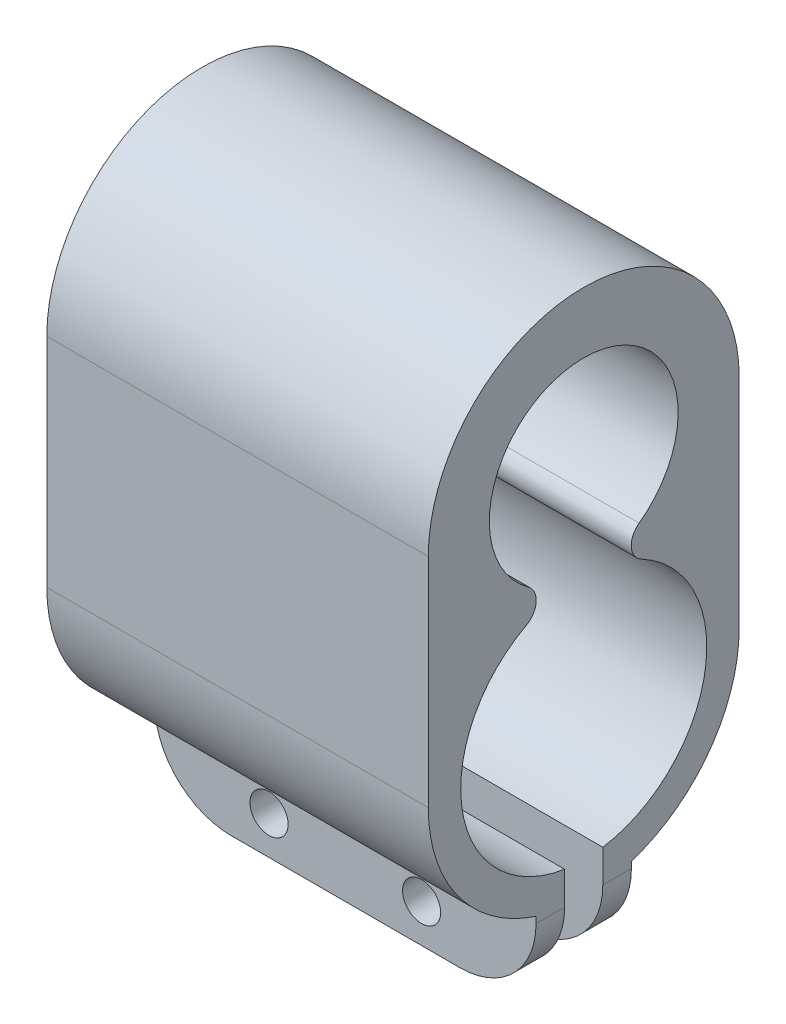
from build123d import *

# Parameters (mm, degrees)
BOSS_EXTRUDE2_DEPTH = 20
SKETCH2_W           = 2
SKETCH2_H           = 9.242730417
CUT_EXTRUDE1_DEPTH  = 20
SKETCH3_W           = 1.5
SKETCH3_H           = 5.716408543
BOSS_EXTRUDE3_DEPTH = 20
SKETCH4_R           = 1
CUT_EXTRUDE2_DEPTH  = 11.65
FILLET1_R           = 4


with BuildPart() as part:
    # Sketch1 → Boss-Extrude2 (new body)
    with BuildSketch(Plane(origin=(0, 0, 0), x_dir=(0, 0, -1), z_dir=(1, 0, 0))):
        with BuildLine():
            Line((8.15, 11.4), (8.15, 0))
            ThreePointArc((8.15, 0), (0, -8.15), (-8.15, 0))
            Line((-8.15, 0), (-8.15, 11.4))
            ThreePointArc((-8.15, 11.4), (0, 19.55), (8.15, 11.4))
        make_face()
        with BuildLine():
            ThreePointArc((2.904067302, 7.391397612), (0, 16.35), (-2.904067302, 7.391397612))
            ThreePointArc((-2.904067302, 7.391397612), (-2.493172041, 6.511986737), (-3.022190844, 5.698145532))
            ThreePointArc((-3.022190844, 5.698145532), (0, -6.45), (3.022190844, 5.698145532))
            ThreePointArc((3.022190844, 5.698145532), (2.493172041, 6.511986737), (2.904067302, 7.391397612))
        make_face(mode=Mode.SUBTRACT)
    extrude(amount=BOSS_EXTRUDE2_DEPTH)

    # Sketch2 → Cut-Extrude1 (cut)
    with BuildSketch(Plane(origin=(20, 0, 0), x_dir=(0, 0, -1), z_dir=(1, 0, 0))):
        with Locations((0, -7.363862564)):
            Rectangle(SKETCH2_W, SKETCH2_H)
    extrude(amount=-CUT_EXTRUDE1_DEPTH, mode=Mode.SUBTRACT)

    # Sketch3 → Boss-Extrude3 (add)
    with BuildSketch(Plane(origin=(20, 0, 0), x_dir=(0, 0, -1), z_dir=(1, 0, 0))):
        with Locations((-1.75, -9.230213374)):
            Rectangle(SKETCH3_W, SKETCH3_H)
        with Locations((1.75, -9.230213374)):
            Rectangle(SKETCH3_W, SKETCH3_H)
    extrude(amount=-BOSS_EXTRUDE3_DEPTH)

    # Sketch4 → Cut-Extrude2 (cut, through all)
    with BuildSketch(Plane(origin=(0, 0, -2.5), x_dir=(-1, 0, 0), z_dir=(0, 0, -1))):
        with Locations((-14, -10.088417645)):
            Circle(SKETCH4_R)
        with Locations((-6, -10.088417645)):
            Circle(SKETCH4_R)
    extrude(amount=-CUT_EXTRUDE2_DEPTH, mode=Mode.SUBTRACT)

    # Fillet1
    fillet1_edges = [part.edges().sort_by_distance(p)[0] for p in [
        (20, -12.088417645, 1.75),
        (0, -12.088417645, 1.75),
        (20, -12.088417645, -1.75),
        (0, -12.088417645, -1.75),
    ]]
    fillet(fillet1_edges, radius=FILLET1_R)


solid = part.part
